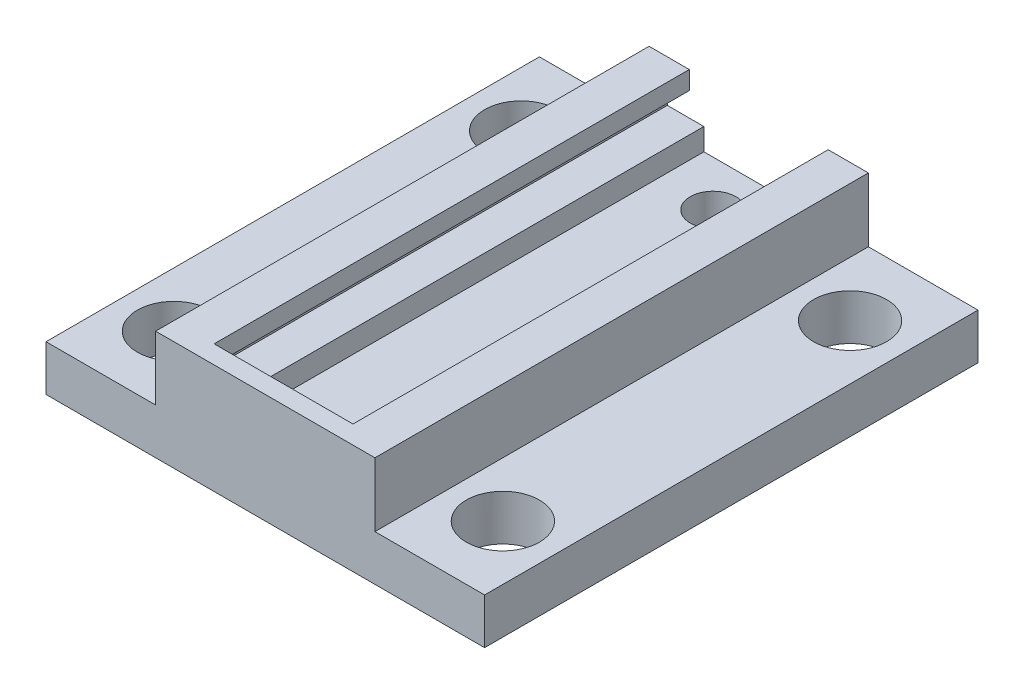
from build123d import *

# Parameters (mm, degrees)
BOSS_EXTRUDE1_DEPTH = 34.29
SKETCH3_W           = 15.24
SKETCH3_H           = 4.445
BOSS_EXTRUDE3_DEPTH = 1.27
SKETCH4_R           = 2.54
CUT_EXTRUDE1_DEPTH  = 7.366092844
SKETCH5_R           = 1.5875
CUT_EXTRUDE2_DEPTH  = 4.175


with BuildPart() as part:
    # Sketch1 → Boss-Extrude1 (new body)
    with BuildSketch(Plane.XY):
        Polygon((3.81, -3.191092844), (-3.81, -3.191092844), (-3.81, -1.667092844), (-6.35, -1.667092844), (-6.35, -0.016092844), (-4.826, -0.016092844), (-4.826, 1.253907156), (-7.62, 1.253907156), (-7.62, -3.191092844), (-15.24, -3.191092844), (-15.24, -6.366092844), (-8.89, -6.366092844), (8.89, -6.366092844), (15.24, -6.366092844), (15.24, -3.191092844), (7.62, -3.191092844), (7.62, 1.253907156), (4.826, 1.253907156), (4.826, -0.016092844), (6.35, -0.016092844), (6.35, -1.667092844), (3.81, -1.667092844), align=None)
    extrude(amount=BOSS_EXTRUDE1_DEPTH)

    # Sketch3 → Boss-Extrude3 (add)
    with BuildSketch(Plane.XY.offset(34.29)):
        with Locations((0, -0.968592844)):
            Rectangle(SKETCH3_W, SKETCH3_H)
    extrude(amount=-BOSS_EXTRUDE3_DEPTH)

    # Sketch4 → Cut-Extrude1 (cut, through all)
    with BuildSketch(Plane(origin=(0, 0, 0), x_dir=(1, 0, 0), z_dir=(0, 1, 0))):
        with Locations((-11.43, -5.08)):
            Circle(SKETCH4_R)
        with Locations((-11.43, -29.21)):
            Circle(SKETCH4_R)
        with Locations((11.43, -29.21)):
            Circle(SKETCH4_R)
        with Locations((11.43, -5.08)):
            Circle(SKETCH4_R)
    extrude(amount=-CUT_EXTRUDE1_DEPTH, mode=Mode.SUBTRACT)

    # Sketch5 → Cut-Extrude2 (cut, through all)
    with BuildSketch(Plane(origin=(0, -3.191092844, 0), x_dir=(1, 0, 0), z_dir=(0, 1, 0))):
        with Locations((0, -3.175)):
            Circle(SKETCH5_R)
    extrude(amount=-CUT_EXTRUDE2_DEPTH, mode=Mode.SUBTRACT)


solid = part.part
